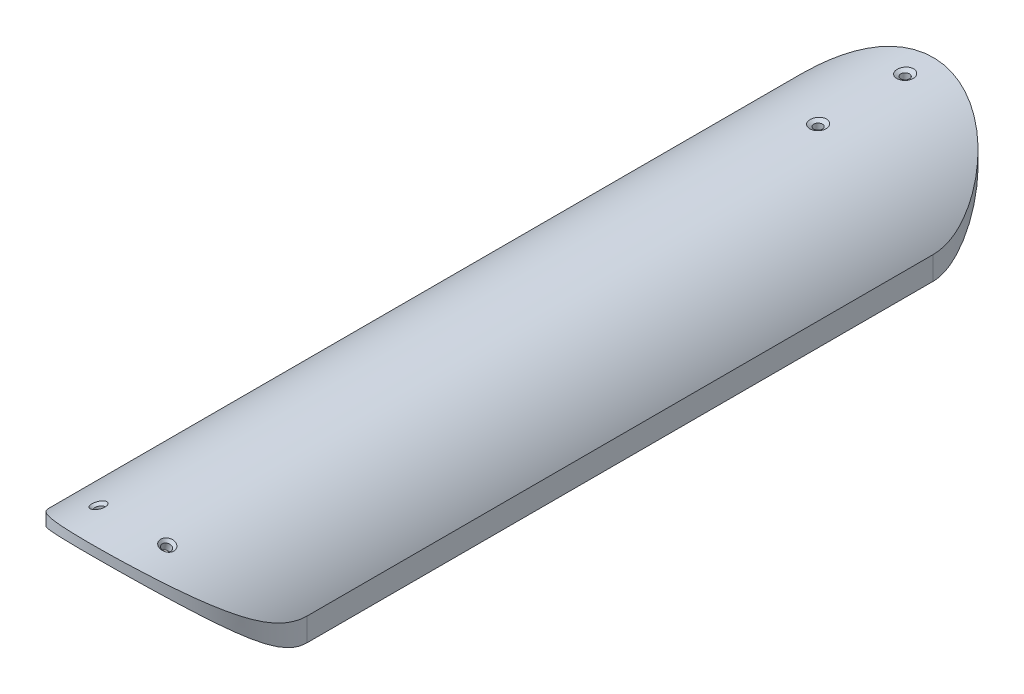
from build123d import *

# Parameters (mm, degrees)
BOSS_EXTRU_1_DEPTH                   = 300
ENL_V_MAT_EXTRU_1_DEPTH              = 45.5
D_GAGEMENT_M21_D                     = 3.1
D_GAGEMENT_M21_CSINK_D               = 6
D_GAGEMENT_M21_CSINK_ANGLE           = 120
R_P_TITION_LIN_AIRE1_COUNT           = 2
R_P_TITION_LIN_AIRE1_PITCH           = 31
D_GAGEMENT_M41_D                     = 3.1
D_GAGEMENT_M41_DEPTH                 = 30
D_GAGEMENT_M41_CSINK_D               = 5
D_GAGEMENT_M41_CSINK_ANGLE           = 90
D_GAGEMENT_M41_TIP                   = 0.931333959
D_GAGEMENT_M41_ON_FACE_2_D           = 3.1
D_GAGEMENT_M41_ON_FACE_2_DEPTH       = 30
D_GAGEMENT_M41_ON_FACE_2_CSINK_D     = 5
D_GAGEMENT_M41_ON_FACE_2_CSINK_ANGLE = 90
D_GAGEMENT_M41_ON_FACE_2_TIP         = 0.931333959


with BuildPart() as part:
    # Esquisse1 → Boss.-Extru.1 (new body)
    with BuildSketch(Plane.XY):
        with BuildLine():
            Line((-38.538130468, 22.25), (-38.538130468, 13.993301969))
            ThreePointArc((-38.538130468, 13.993301969), (0, 41), (38.538130468, 13.993301969))
            Line((38.538130468, 13.993301969), (38.538130468, 22.25))
            ThreePointArc((38.538130468, 22.25), (0, 44.5), (-38.538130468, 22.25))
        make_face()
    extrude(amount=BOSS_EXTRU_1_DEPTH)

    # Esquisse2 → Enlèv. mat.-Extru.1 (cut, through all)
    with BuildSketch(Plane(origin=(0, 0, 0), x_dir=(1, 0, 0), z_dir=(0, 1, 0))):
        with BuildLine():
            Line((38.538130468, -261.46), (70.818354585, -261.46))
            Line((70.818354585, -261.46), (70.818354585, -316.268787276))
            Line((70.818354585, -316.268787276), (-50.118143928, -316.268787276))
            Line((-50.118143928, -316.268787276), (-50.118143928, -261.46))
            Line((-50.118143928, -261.46), (-38.538130468, -261.46))
            ThreePointArc((-38.538130468, -261.46), (0, -299.998130468), (38.538130468, -261.46))
        make_face()
    enl_v_mat_extru_1 = extrude(amount=ENL_V_MAT_EXTRU_1_DEPTH, mode=Mode.SUBTRACT)

    # Symétrie1: Enlèv. mat.-Extru.1 across plane
    add(enl_v_mat_extru_1.mirror(Plane.XY.offset(150)), mode=Mode.SUBTRACT)

    # Dégagement M21 (through all)
    with Locations(Plane(origin=(0.001869532, 44.499999961, 10), x_dir=(0.999999999, -4.2012e-05, 0), z_dir=(4.2012e-05, 0.999999999, 0))):
        with Locations((0, 0)):
            d_gagement_m21 = CounterSinkHole(D_GAGEMENT_M21_D / 2, D_GAGEMENT_M21_CSINK_D / 2, counter_sink_angle=D_GAGEMENT_M21_CSINK_ANGLE)

    # Répétition linéaire1: Dégagement M21 ×2
    with Locations(*[(0, 0, i * R_P_TITION_LIN_AIRE1_PITCH) for i in range(1, R_P_TITION_LIN_AIRE1_COUNT)]):
        add(d_gagement_m21, mode=Mode.SUBTRACT)

    # Dégagement M41
    with Locations(Plane(origin=(-12.265862334, 42.776145469, 285), x_dir=(0.961261696, 0.275637356, 0), z_dir=(-0.275637356, 0.961261696, 0))):
        with Locations((0, 0)):
            CounterSinkHole(D_GAGEMENT_M41_D / 2, D_GAGEMENT_M41_CSINK_D / 2, depth=D_GAGEMENT_M41_DEPTH, counter_sink_angle=D_GAGEMENT_M41_CSINK_ANGLE)
            with Locations((0, 0, -(D_GAGEMENT_M41_DEPTH + D_GAGEMENT_M41_TIP / 2))):  # 118° drill point
                Cone(0, D_GAGEMENT_M41_D / 2, D_GAGEMENT_M41_TIP, mode=Mode.SUBTRACT)

    # Dégagement M41 on face 2
    with Locations(Plane(origin=(12.265862334, 42.776145469, 285), x_dir=(0.961261813, -0.275636946, 0), z_dir=(0.275636946, 0.961261813, 0))):
        with Locations((0, 0)):
            CounterSinkHole(D_GAGEMENT_M41_ON_FACE_2_D / 2, D_GAGEMENT_M41_ON_FACE_2_CSINK_D / 2, depth=D_GAGEMENT_M41_ON_FACE_2_DEPTH, counter_sink_angle=D_GAGEMENT_M41_ON_FACE_2_CSINK_ANGLE)
            with Locations((0, 0, -(D_GAGEMENT_M41_ON_FACE_2_DEPTH + D_GAGEMENT_M41_ON_FACE_2_TIP / 2))):  # 118° drill point
                Cone(0, D_GAGEMENT_M41_ON_FACE_2_D / 2, D_GAGEMENT_M41_ON_FACE_2_TIP, mode=Mode.SUBTRACT)


solid = part.part
